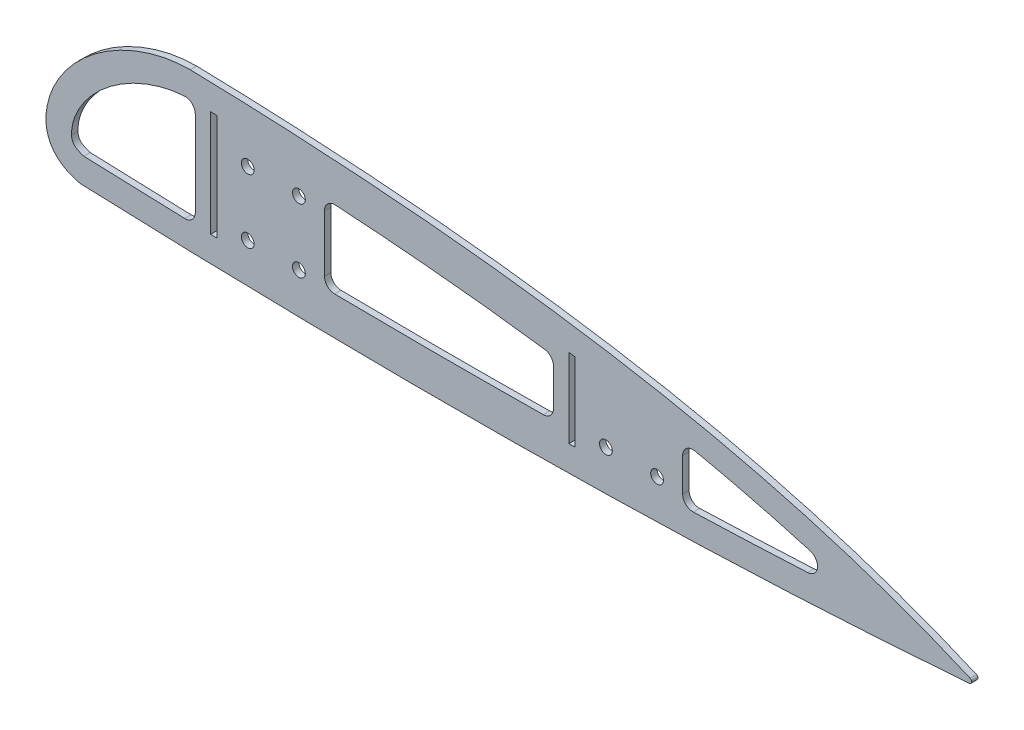
from build123d import *

# Parameters (mm, degrees)
BOSS_EXTRUDE1_DEPTH = 3.175
CUT_EXTRUDE1_DEPTH  = 4.1750001
SKETCH6_R           = 3.175
BOSS_EXTRUDE7_DEPTH = 3.175
FILLET1_R           = 5.08
FILLET2_R           = 1.27


with BuildPart() as part:
    # Sketch1 → Boss-Extrude1 (new body)
    with BuildSketch(Plane.XY):
        with BuildLine():
            add(Edge.make_bspline(
                [(2208.826149834, -26.774098628), (2193.539216523, -19.989502093), (2178.017285603, -13.876667427), (2146.547339096, -2.86899956), (2130.599958623, 2.027649171), (2110.435986102, 7.491707758), (2106.393554928, 8.55118928), (2098.297614737, 10.604542613), (2094.242974563, 11.598723701), (2082.059971833, 14.488301409), (2073.912539424, 16.290792682), (2049.400960152, 21.360735169), (2032.967750876, 24.291725069), (2008.204000471, 28.133129093), (1999.935430971, 29.319983431), (1983.389966503, 31.521893365), (1975.110327846, 32.537373512), (1950.252618166, 35.351220411), (1933.65583393, 36.917989904), (1900.420502754, 39.534667952), (1883.781942961, 40.584417458), (1850.468809571, 42.238204696), (1833.79422398, 42.842094001), (1817.103471978, 43.245905599)],
                knots=[0, 0, 0, 0, 0.125, 0.125, 0.25, 0.25, 0.28125, 0.28125, 0.3125, 0.3125, 0.375, 0.375, 0.5, 0.5, 0.5625, 0.5625, 0.625, 0.625, 0.75, 0.75, 0.875, 0.875, 1, 1, 1, 1], degree=3))
            add(Edge.make_bspline(
                [(1817.103471978, 43.245905599), (1814.993435483, 43.249818911), (1812.902281774, 43.14073144), (1808.751971163, 42.731077116), (1806.692858832, 42.43024354), (1802.603452309, 41.656119196), (1800.573177775, 41.182710789), (1797.548141558, 40.350664005), (1796.543202515, 40.052930289), (1794.540039393, 39.417278311), (1793.543651663, 39.07987044), (1788.61281714, 37.306681043), (1784.805031282, 35.607949465), (1779.288207667, 32.661007626), (1777.482053008, 31.611583671), (1774.823435143, 29.933846874), (1773.944680771, 29.356602452), (1772.209406425, 28.169853719), (1771.35408521, 27.56122969), (1768.825522581, 25.68904753), (1767.189552324, 24.37934012), (1764.81418647, 22.317469168), (1764.035523773, 21.613926288), (1762.505563302, 20.172957184), (1761.754241662, 19.435347934), (1759.559625835, 17.186266131), (1758.169757366, 15.633512849), (1755.547298701, 12.41335851), (1754.314574941, 10.746054815), (1752.026226788, 7.282351094), (1750.970301104, 5.486170694), (1749.54544678, 2.675972337), (1749.0957004, 1.716092571), (1748.266981351, -0.221543528), (1747.887119288, -1.200435153), (1746.858662611, -4.169560869), (1746.319774796, -6.191830355), (1745.782085259, -9.30426459), (1745.64817617, -10.358945896), (1745.486484448, -12.470000764), (1745.458025679, -13.527966572), (1745.487387058, -14.588623636)],
                knots=[0, 0, 0, 0, 0.0625, 0.0625, 0.125, 0.125, 0.1875, 0.1875, 0.21875, 0.21875, 0.25, 0.25, 0.375, 0.375, 0.4375, 0.4375, 0.46875, 0.46875, 0.5, 0.5, 0.5625, 0.5625, 0.59375, 0.59375, 0.625, 0.625, 0.6875, 0.6875, 0.75, 0.75, 0.8125, 0.8125, 0.84375, 0.84375, 0.875, 0.875, 0.9375, 0.9375, 0.96875, 0.96875, 1, 1, 1, 1], degree=3))
            add(Edge.make_bspline(
                [(1745.487387058, -14.588623636), (1745.519066316, -15.733015093), (1745.638906007, -16.860763602), (1745.965610527, -18.524646056), (1746.099084693, -19.074634709), (1746.418822982, -20.164646312), (1746.60632169, -20.707604584), (1747.245568232, -22.297609314), (1747.76923172, -23.298186294), (1748.698992912, -24.711120987), (1749.033013372, -25.167410118), (1749.74957667, -26.050413763), (1750.134247386, -26.479012593), (1751.336986575, -27.69587901), (1752.207492266, -28.422271799), (1753.603167879, -29.4007712), (1754.084371804, -29.708878166), (1755.071395942, -30.287457349), (1755.572970699, -30.555577014), (1757.099298482, -31.303212413), (1758.14552662, -31.726341674), (1760.285790974, -32.447072162), (1761.379887357, -32.744515407), (1762.494942852, -32.986927029)],
                knots=[0, 0, 0, 0, 0.125, 0.125, 0.1875, 0.1875, 0.25, 0.25, 0.375, 0.375, 0.4375, 0.4375, 0.5, 0.5, 0.625, 0.625, 0.6875, 0.6875, 0.75, 0.75, 0.875, 0.875, 1, 1, 1, 1], degree=3))
            add(Edge.make_bspline(
                [(1762.494942852, -32.986927029), (1799.691236169, -34.462268422), (1836.898314249, -35.53601849), (1892.727472404, -36.456232521), (1911.339681386, -36.647469536), (1948.561568057, -36.779321796), (1967.172285553, -36.719952722), (2004.393227643, -36.32775237), (2023.005145642, -35.994828565), (2060.211460542, -35.030119446), (2078.807459794, -34.398285512), (2134.572042281, -32.013819946), (2171.717072663, -29.769351472), (2208.826149834, -26.774098628)],
                knots=[0, 0, 0, 0, 0.25, 0.25, 0.375, 0.375, 0.5, 0.5, 0.625, 0.625, 0.75, 0.75, 1, 1, 1, 1], degree=3))
        make_face()
    extrude(amount=BOSS_EXTRUDE1_DEPTH)

    # Sketch2 → Cut-Extrude1 (cut, through all)
    with BuildSketch(Plane.XY.offset(3.175)):
        with BuildLine():
            Line((1830.3875, 28.45362069), (1830.3875, 30.175727689))
            add(Edge.make_bspline(
                [(1830.3875, 30.175727689), (1829.329217217, 30.208388946), (1828.270883761, 30.240213985), (1827.2125, 30.271208865)],
                knots=[0.960385702, 0.960385702, 0.960385702, 0.960385702, 0.969744675, 0.969744675, 0.969744675, 0.969744675], degree=3))
            Line((1827.2125, 30.271208865), (1827.2125, 29.347074508))
            add(Edge.make_bspline(
                [(1830.3875, 28.45362069), (1829.319253551, 28.797696625), (1828.261177299, 29.094314935), (1827.2125, 29.347074508)],
                knots=[-0.160424535, -0.160424535, -0.160424535, -0.160424535, -0.123585954, -0.123585954, -0.123585954, -0.123585954], degree=3))
        make_face()
        with BuildLine():
            Line((1830.3875, -22.516004669), (1830.3875, 28.45362069))
            add(Edge.make_bspline(
                [(1830.3875, 28.45362069), (1829.319253551, 28.797696625), (1828.261177299, 29.094314935), (1827.2125, 29.347074508)],
                knots=[-0.160424535, -0.160424535, -0.160424535, -0.160424535, -0.123585954, -0.123585954, -0.123585954, -0.123585954], degree=3))
            Line((1827.2125, 29.347074508), (1827.2125, -22.432376857))
            add(Edge.make_bspline(
                [(1827.2125, -22.432376857), (1828.270823436, -22.46060644), (1829.329156756, -22.488482831), (1830.3875, -22.516004669)],
                knots=[0.162616509, 0.162616509, 0.162616509, 0.162616509, 0.170814514, 0.170814514, 0.170814514, 0.170814514], degree=3))
        make_face()
        with BuildLine():
            add(Edge.make_bspline(
                [(1997.3925, 16.822922555), (1993.630882942, 17.347588033), (1989.866618103, 17.853957533), (1979.090477297, 19.252724256), (1972.072359095, 20.101988067), (1958.019975072, 21.688936807), (1950.984277811, 22.426910762), (1929.867384549, 24.484110321), (1915.77684507, 25.647472037), (1887.574109582, 27.616812618), (1873.461842332, 28.421615862), (1852.231569693, 29.393924214), (1845.120699933, 29.679183675), (1838.0075, 29.925989897)],
                knots=[0.466412846, 0.466412846, 0.466412846, 0.466412846, 0.5, 0.5, 0.5625, 0.5625, 0.625, 0.625, 0.75, 0.75, 0.875, 0.875, 0.937920499, 0.937920499, 0.937920499, 0.937920499], degree=3))
            Line((1838.0075, 29.925989897), (1838.0075, 25.241788294))
            add(Edge.make_bspline(
                [(1883.230692695, -23.589147972), (1865.719711451, 4.057765355), (1851.051821199, 18.437841657), (1838.0075, 25.241788294)],
                knots=[-0.675188539, -0.675188539, -0.675188539, -0.675188539, -0.246012372, -0.246012372, -0.246012372, -0.246012372], degree=3))
            add(Edge.make_bspline(
                [(1883.230692695, -23.589147972), (1908.122308679, -23.949750113), (1933.016441929, -24.100442543), (1971.070756412, -23.972377714), (1984.232598527, -23.862402857), (1997.3925, -23.682483467)],
                knots=[0.307236978, 0.307236978, 0.307236978, 0.307236978, 0.5, 0.5, 0.601910533, 0.601910533, 0.601910533, 0.601910533], degree=3))
            Line((1997.3925, -23.682483467), (1997.3925, 16.822922555))
        make_face()
        with BuildLine():
            add(Edge.make_bspline(
                [(1883.230692695, -23.589147972), (1865.719711451, 4.057765355), (1851.051821199, 18.437841657), (1838.0075, 25.241788294)],
                knots=[-0.675188539, -0.675188539, -0.675188539, -0.675188539, -0.246012372, -0.246012372, -0.246012372, -0.246012372], degree=3))
            Line((1838.0075, 25.241788294), (1838.0075, -22.708010461))
            add(Edge.make_bspline(
                [(1838.0075, -22.708010461), (1845.690565464, -22.89538616), (1853.374158656, -23.063906156), (1868.448817248, -23.356494226), (1875.839644001, -23.482074651), (1883.230692695, -23.589147972)],
                knots=[0.190489098, 0.190489098, 0.190489098, 0.190489098, 0.25, 0.25, 0.307236978, 0.307236978, 0.307236978, 0.307236978], degree=3))
        make_face()
        with BuildLine():
            Line((1819.5925, 30.472080515), (1819.5925, 30.480079213))
            add(Edge.make_bspline(
                [(1819.5925, 30.480079213), (1819.499941132, 30.482443901), (1819.407381886, 30.484802354), (1819.314822262, 30.487154575)],
                knots=[0.992202591, 0.992202591, 0.992202591, 0.992202591, 0.993020877, 0.993020877, 0.993020877, 0.993020877], degree=3))
            add(Edge.make_bspline(
                [(1819.5925, 30.472080515), (1819.499877564, 30.47740007), (1819.407318518, 30.482423824), (1819.314822262, 30.487154575)],
                knots=[-0.032476302, -0.032476302, -0.032476302, -0.032476302, -0.029087617, -0.029087617, -0.029087617, -0.029087617], degree=3))
        make_face()
        with BuildLine():
            Line((1819.5925, -22.223032698), (1819.5925, 30.472080515))
            add(Edge.make_bspline(
                [(1819.5925, 30.472080515), (1819.499877564, 30.47740007), (1819.407318518, 30.482423824), (1819.314822262, 30.487154575)],
                knots=[-0.032476302, -0.032476302, -0.032476302, -0.032476302, -0.029087617, -0.029087617, -0.029087617, -0.029087617], degree=3))
            add(Edge.make_bspline(
                [(1819.314822262, 30.487154575), (1818.525385041, 30.507216576), (1817.735920353, 30.526825309), (1816.946428351, 30.545983287)],
                knots=[0.993020877, 0.993020877, 0.993020877, 0.993020877, 1, 1, 1, 1], degree=3))
            add(Edge.make_bspline(
                [(1816.946428351, 30.545983287), (1815.259517839, 30.5442689), (1813.592213944, 30.451063323), (1810.289286646, 30.116820127), (1808.65376926, 29.875287801), (1803.788899639, 28.956185819), (1800.600751861, 28.086342046), (1796.676408521, 26.715130586), (1795.894616004, 26.426533917), (1794.337128797, 25.820886031), (1793.560109445, 25.503141586), (1791.252941064, 24.512864699), (1789.744211153, 23.802569464), (1785.302377009, 21.527818004), (1782.452416453, 19.821562902), (1779.035811812, 17.440008253), (1778.359857571, 16.951133674), (1777.023114776, 15.947519924), (1776.361321142, 15.431941689), (1774.40739687, 13.850775499), (1773.149823735, 12.753968954), (1770.729423729, 10.470547045), (1769.566529003, 9.283995999), (1767.345255497, 6.811824525), (1766.286706638, 5.526365313), (1764.789963264, 3.511842961), (1764.305320722, 2.824148818), (1763.375307227, 1.425204468), (1762.930474085, 0.715212279), (1761.662717456, -1.449568936), (1760.904945699, -2.938332908), (1759.933852798, -5.2578166), (1759.637095704, -6.049079018), (1759.115616491, -7.64556637), (1758.890924459, -8.450241371), (1758.681348213, -9.381376213), (1758.65545467, -9.500519492), (1758.630475164, -9.619825845)],
                knots=[0, 0, 0, 0, 0.0625, 0.0625, 0.125, 0.125, 0.25, 0.25, 0.28125, 0.28125, 0.3125, 0.3125, 0.375, 0.375, 0.5, 0.5, 0.53125, 0.53125, 0.5625, 0.5625, 0.625, 0.625, 0.6875, 0.6875, 0.75, 0.75, 0.78125, 0.78125, 0.8125, 0.8125, 0.875, 0.875, 0.90625, 0.90625, 0.9375, 0.9375, 0.942078319, 0.942078319, 0.942078319, 0.942078319], degree=3))
            add(Edge.make_bspline(
                [(1758.630475164, -9.619825845), (1758.484953327, -10.314862771), (1758.370452199, -11.015434169), (1758.200707969, -12.550912317), (1758.159022796, -13.388237968), (1758.182523802, -14.237193626)],
                knots=[0.942078319, 0.942078319, 0.942078319, 0.942078319, 0.96875, 0.96875, 1, 1, 1, 1], degree=3))
            add(Edge.make_bspline(
                [(1758.182523802, -14.237193626), (1758.193391857, -14.629794663), (1758.228245946, -15.017712539), (1758.363087246, -15.780831349), (1758.462365589, -16.156170687), (1758.686033295, -16.704585066), (1758.772487828, -16.882430937), (1758.967639948, -17.220340603), (1759.076634268, -17.381567748), (1759.436065983, -17.843288404), (1759.721090775, -18.123230605), (1760.326294439, -18.616854651), (1760.649329786, -18.835235199), (1761.323953366, -19.232267414), (1761.676079949, -19.410494739), (1762.746939471, -19.890084236), (1763.487097139, -20.141118998), (1764.244817896, -20.346196602)],
                knots=[0, 0, 0, 0, 0.125, 0.125, 0.25, 0.25, 0.3125, 0.3125, 0.375, 0.375, 0.5, 0.5, 0.625, 0.625, 0.75, 0.75, 1, 1, 1, 1], degree=3))
            add(Edge.make_bspline(
                [(1764.244817896, -20.346196602), (1782.691202535, -21.073379034), (1801.140362568, -21.701396949), (1819.5925, -22.223032698)],
                knots=[0, 0, 0, 0, 0.142940674, 0.142940674, 0.142940674, 0.142940674], degree=3))
        make_face()
        with BuildLine():
            add(Edge.make_bspline(
                [(2008.1875, 15.265166758), (2007.129385315, 15.423044414), (2006.071051051, 15.579404789), (2005.0125, 15.734267187)],
                knots=[0.434261648, 0.434261648, 0.434261648, 0.434261648, 0.4437225, 0.4437225, 0.4437225, 0.4437225], degree=3))
            Line((2005.0125, 15.734267187), (2005.0125, -23.570453109))
            add(Edge.make_bspline(
                [(2005.0125, -23.570453109), (2005.453978504, -23.563505723), (2005.895454173, -23.556478685), (2006.953790055, -23.539441537), (2007.570647763, -23.529355343), (2008.1875, -23.519112774)],
                knots=[0.621580958, 0.621580958, 0.621580958, 0.621580958, 0.625, 0.625, 0.629777375, 0.629777375, 0.629777375, 0.629777375], degree=3))
            Line((2008.1875, -23.519112774), (2008.1875, 15.265166758))
        make_face()
        with BuildLine():
            add(Edge.make_bspline(
                [(2151.489823197, -18.092636652), (2124.659895132, -9.034261502), (2097.362514894, -1.772752147), (2062.809776149, 5.647337626), (2055.875567916, 7.048663296), (2041.97666459, 9.696152751), (2035.015867752, 10.94150313), (2023.969101929, 12.801134125), (2019.889988679, 13.462787395), (2015.8075, 14.101116685)],
                knots=[0, 0, 0, 0, 0.25, 0.25, 0.3125, 0.3125, 0.375, 0.375, 0.411539471, 0.411539471, 0.411539471, 0.411539471], degree=3))
            Line((2015.8075, 14.101116685), (2015.8075, -23.384593009))
            add(Edge.make_bspline(
                [(2015.8075, -23.384593009), (2028.789535516, -23.141739099), (2041.769116983, -22.828738936), (2087.010994016, -21.477389335), (2119.259727725, -20.051389477), (2151.489823197, -18.092636652)],
                knots=[0.649449799, 0.649449799, 0.649449799, 0.649449799, 0.75, 0.75, 1, 1, 1, 1], degree=3))
        make_face()
    extrude(amount=-CUT_EXTRUDE1_DEPTH, mode=Mode.SUBTRACT)

    # Sketch6 → Boss-Extrude7 (add)
    with BuildSketch(Plane.XY.offset(3.175)):
        with BuildLine():
            Line((1838.0075, 23.572156428), (1838.0075, -22.708010461))
            add(Edge.make_bspline(
                [(1838.0075, -22.708010461), (1845.690565464, -22.89538616), (1853.374158656, -23.063906156), (1868.614407795, -23.359708217), (1876.170838856, -23.487693142), (1883.7275, -23.596317281)],
                knots=[0.398089467, 0.398089467, 0.398089467, 0.398089467, 0.457600369, 0.457600369, 0.516119787, 0.516119787, 0.516119787, 0.516119787], degree=3))
            Line((1883.7275, -23.596317281), (1883.7275, -17.245643568))
            Line((1883.7275, -17.245643568), (1883.7275, 21.42844463))
            add(Edge.make_bspline(
                [(1883.7275, 21.42844463), (1881.68718461, 21.549755556), (1866.459686845, 22.428371407), (1851.212368207, 23.112511636), (1838.0075, 23.572156428)],
                knots=[0.39756974, 0.39756974, 0.39756974, 0.39756974, 0.415710241, 0.532935571, 0.532935571, 0.532935571, 0.532935571], degree=3))
        make_face()
        with BuildLine():
            ThreePointArc((1848.8025, -15.875000087), (1848.781139707, -16.242670586), (1848.717346239, -16.605393967))
            ThreePointArc((1848.717346239, -16.605393967), (1845.555151549, -19.049175681), (1842.507584324, -16.463855907))
            ThreePointArc((1842.507584324, -16.463855907), (1845.331786684, -12.713801163), (1848.8025, -15.875000087))
        make_face(mode=Mode.SUBTRACT)
        with BuildLine():
            ThreePointArc((1874.2025, -15.875000087), (1874.141039193, -16.496690279), (1873.959036255, -17.094311443))
            ThreePointArc((1873.959036255, -17.094311443), (1870.972765421, -19.04952826), (1868.05567245, -16.992526827))
            ThreePointArc((1868.05567245, -16.992526827), (1870.459577237, -12.751206122), (1874.2025, -15.875000087))
        make_face(mode=Mode.SUBTRACT)
        with Locations((1845.6275, 15.874999913)):
            Circle(SKETCH6_R, mode=Mode.SUBTRACT)
        with Locations((1871.0275, 15.874999913)):
            Circle(SKETCH6_R, mode=Mode.SUBTRACT)
        with BuildLine():
            Line((1838.0075, 29.925989897), (1838.0075, 23.572156428))
            add(Edge.make_bspline(
                [(1883.7275, 21.42844463), (1881.68718461, 21.549755556), (1866.459686845, 22.428371407), (1851.212368207, 23.112511636), (1838.0075, 23.572156428)],
                knots=[0.39756974, 0.39756974, 0.39756974, 0.39756974, 0.415710241, 0.532935571, 0.532935571, 0.532935571, 0.532935571], degree=3))
            Line((1883.7275, 21.42844463), (1883.7275, 27.789610402))
            add(Edge.make_bspline(
                [(1883.7275, 27.789610402), (1875.60167708, 28.271055857), (1867.472425493, 28.695920395), (1852.231569693, 29.393924214), (1845.120699933, 29.679183675), (1838.0075, 29.925989897)],
                knots=[0.398682187, 0.398682187, 0.398682187, 0.398682187, 0.470666655, 0.470666655, 0.533587154, 0.533587154, 0.533587154, 0.533587154], degree=3))
        make_face()
        with BuildLine():
            Line((1883.7275, -17.245643568), (1883.7275, -23.596317281))
            add(Edge.make_bspline(
                [(1883.7275, -23.596317281), (1908.453546795, -23.951744829), (1933.182056979, -24.099885196), (1971.070756412, -23.972377714), (1984.232598527, -23.862402857), (1997.3925, -23.682483467)],
                knots=[0.516119787, 0.516119787, 0.516119787, 0.516119787, 0.707600369, 0.707600369, 0.809510902, 0.809510902, 0.809510902, 0.809510902], degree=3))
            Line((1997.3925, -23.682483467), (1997.3925, -17.331890031))
            Line((1997.3925, -17.331890031), (1997.305692255, -17.333076848))
            add(Edge.make_bspline(
                [(1883.7275, -17.245643568), (1895.063954929, -17.408810691), (1919.663236662, -17.668285198), (1957.523840288, -17.734582997), (1984.045611449, -17.514365869), (1997.305692255, -17.333076848)],
                knots=[0.515883794, 0.515883794, 0.515883794, 0.515883794, 0.603800184, 0.706655543, 0.809510902, 0.809510902, 0.809510902, 0.809510902], degree=3))
        make_face()
        with BuildLine():
            Line((1883.7275, 27.789610402), (1883.7275, 21.42844463))
            add(Edge.make_bspline(
                [(1996.515301761, 10.533803121), (1983.376915498, 12.366328233), (1957.048257164, 15.58294715), (1919.398614862, 19.070987997), (1894.945147221, 20.761477562), (1883.7275, 21.42844463)],
                knots=[0.062079501, 0.062079501, 0.062079501, 0.062079501, 0.179956414, 0.297833328, 0.39756974, 0.39756974, 0.39756974, 0.39756974], degree=3))
            Line((1996.515301761, 10.533803121), (1997.3925, 10.411452646))
            Line((1997.3925, 10.411452646), (1997.3925, 16.822922555))
            add(Edge.make_bspline(
                [(1997.392500001, 16.822922554), (1993.630882942, 17.347588033), (1989.866618103, 17.853957533), (1979.090477297, 19.252724256), (1972.072359095, 20.101988067), (1958.019975072, 21.688936807), (1950.984277811, 22.426910762), (1929.867384549, 24.484110321), (1915.77684507, 25.647472037), (1895.694745212, 27.049764882), (1889.712052479, 27.435032704), (1883.7275, 27.789610402)],
                knots=[0.062079501, 0.062079501, 0.062079501, 0.062079501, 0.095666655, 0.095666655, 0.158166655, 0.158166655, 0.220666655, 0.220666655, 0.345666655, 0.345666655, 0.398682187, 0.398682187, 0.398682187, 0.398682187], degree=3))
        make_face()
        with BuildLine():
            Line((2015.8075, 14.101116685), (2015.8075, -23.384593009))
            add(Edge.make_bspline(
                [(2015.8075, -23.384593009), (2028.789535516, -23.141739099), (2041.769116983, -22.828738936), (2057.006638382, -22.373602681), (2059.267109307, -22.30381218), (2061.5275, -22.23172831)],
                knots=[0, 0, 0, 0, 0.100550201, 0.100550201, 0.118065751, 0.118065751, 0.118065751, 0.118065751], degree=3))
            Line((2061.5275, -22.23172831), (2061.5275, 5.882110535))
            add(Edge.make_bspline(
                [(2061.5275, 5.882110535), (2057.33386881, 6.741392474), (2053.132785257, 7.571113737), (2041.97666459, 9.696152751), (2035.015867752, 10.94150313), (2023.969101929, 12.801134125), (2019.889988679, 13.462787395), (2015.8075, 14.101116685)],
                knots=[0.863127787, 0.863127787, 0.863127787, 0.863127787, 0.900960529, 0.900960529, 0.963460529, 0.963460529, 1, 1, 1, 1], degree=3))
        make_face()
        with Locations((2023.4275, -15.875000087)):
            Circle(SKETCH6_R, mode=Mode.SUBTRACT)
        with Locations((2048.8275, -15.875000087)):
            Circle(SKETCH6_R, mode=Mode.SUBTRACT)
    extrude(amount=-BOSS_EXTRUDE7_DEPTH)

    # Fillet1
    fillet1_edges = [part.edges().sort_by_distance(p)[0] for p in [
        (2151.489823197, -18.092636652, 1.5875),
        (1819.5925, -22.223032698, 1.5875),
        (1819.5925, 30.480079213, 1.5875),
        (2061.5275, -22.23172831, 1.5875),
        (2061.5275, 5.882110535, 1.5875),
        (1997.3925, -17.331890031, 1.5875),
        (1997.3925, 10.411452646, 1.5875),
        (1883.7275, 21.42844463, 1.5875),
        (1883.7275, -17.245643568, 1.5875),
    ]]
    fillet(fillet1_edges, radius=FILLET1_R)

    # Fillet2
    fillet2_edges = [part.edges().sort_by_distance(p)[0] for p in [
        (2208.826149834, -26.774098628, 1.5875),
    ]]
    fillet(fillet2_edges, radius=FILLET2_R)


solid = part.part
